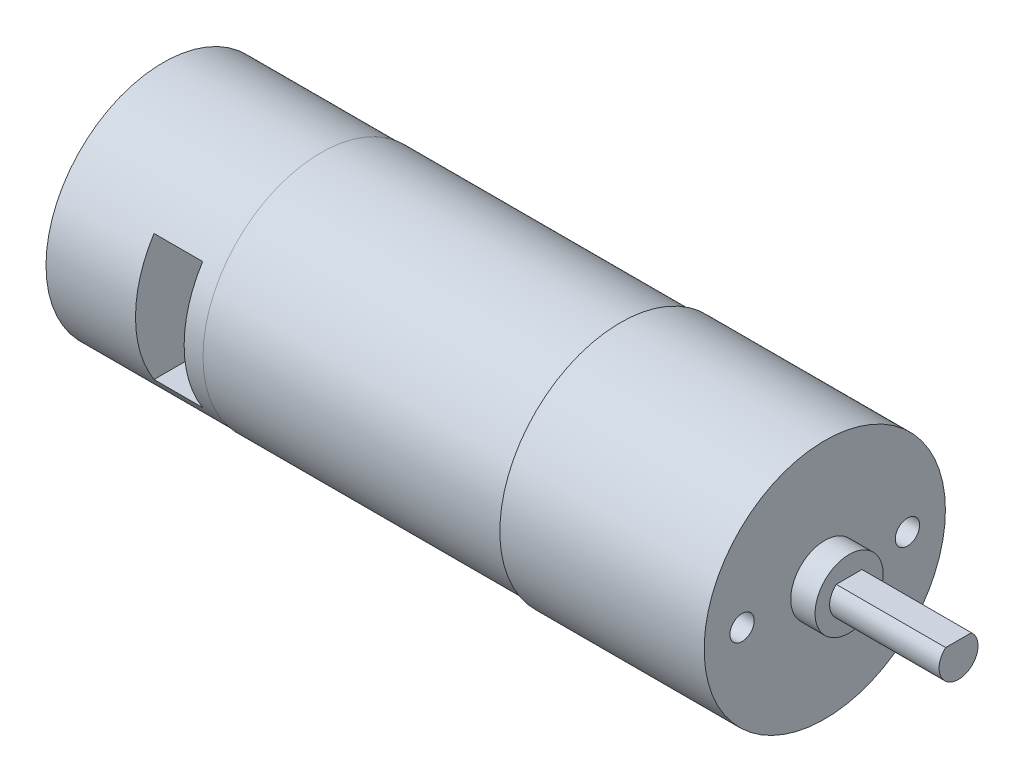
from build123d import *

# Parameters (mm, degrees)
SKETCH1_R                 = 12.4
BOSS_EXTRUDE2_DEPTH       = 21
SKETCH3_R                 = 12.115
BOSS_EXTRUDE3_DEPTH       = 30.8
SKETCH4_R                 = 12.05
BOSS_EXTRUDE4_DEPTH       = 16.2
SKETCH5_R                 = 3.5
BOSS_EXTRUDE5_DEPTH       = 2.5
BOSS_EXTRUDE6_DEPTH       = 11.25
M3X0_5_TAPPED_HOLE1_D     = 2.5
M3X0_5_TAPPED_HOLE1_DEPTH = 4
M3X0_5_TAPPED_HOLE1_TIP   = 0.751075774
SKETCH9_W                 = 5
SKETCH9_H                 = 13
CUT_EXTRUDE2_DEPTH        = 13.4


with BuildPart() as part:
    # Sketch1 → Boss-Extrude2 (new body)
    with BuildSketch(Plane(origin=(0, 0, 0), x_dir=(0, 0, -1), z_dir=(1, 0, 0))):
        Circle(SKETCH1_R)
    extrude(amount=-BOSS_EXTRUDE2_DEPTH)

    # Sketch3 → Boss-Extrude3 (add)
    with BuildSketch(Plane.ZY.offset(21)):
        Circle(SKETCH3_R)
    extrude(amount=BOSS_EXTRUDE3_DEPTH)

    # Sketch4 → Boss-Extrude4 (add)
    with BuildSketch(Plane.ZY.offset(51.8)):
        Circle(SKETCH4_R)
    extrude(amount=BOSS_EXTRUDE4_DEPTH)

    # Sketch5 → Boss-Extrude5 (add)
    with BuildSketch(Plane(origin=(0, 0, 0), x_dir=(0, 0, -1), z_dir=(1, 0, 0))):
        Circle(SKETCH5_R)
    extrude(amount=BOSS_EXTRUDE5_DEPTH)

    # Sketch6 → Boss-Extrude6 (add)
    with BuildSketch(Plane(origin=(2.5, 0, 0), x_dir=(0, 0, -1), z_dir=(1, 0, 0))):
        with BuildLine():
            Line((-1.322875656, 1.5), (1.322875656, 1.5))
            ThreePointArc((1.322875656, 1.5), (0, -2), (-1.322875656, 1.5))
        make_face()
    extrude(amount=BOSS_EXTRUDE6_DEPTH)

    # M3x0.5 Tapped Hole1
    with Locations(Plane(origin=(0, 0, 0), x_dir=(0, 0, -1), z_dir=(1, 0, 0))):
        with Locations((-8.5, 0), (8.5, 0)):
            Hole(M3X0_5_TAPPED_HOLE1_D / 2, depth=M3X0_5_TAPPED_HOLE1_DEPTH)
            with Locations((0, 0, -(M3X0_5_TAPPED_HOLE1_DEPTH + M3X0_5_TAPPED_HOLE1_TIP / 2))):  # 118° drill point
                Cone(0, M3X0_5_TAPPED_HOLE1_D / 2, M3X0_5_TAPPED_HOLE1_TIP, mode=Mode.SUBTRACT)

    # Sketch9 → Cut-Extrude2 (cut, through all)
    with BuildSketch(Plane.XY):
        with Locations((-56.3, 0)):
            Rectangle(SKETCH9_W, SKETCH9_H)
    extrude(amount=CUT_EXTRUDE2_DEPTH, mode=Mode.SUBTRACT)


solid = part.part
